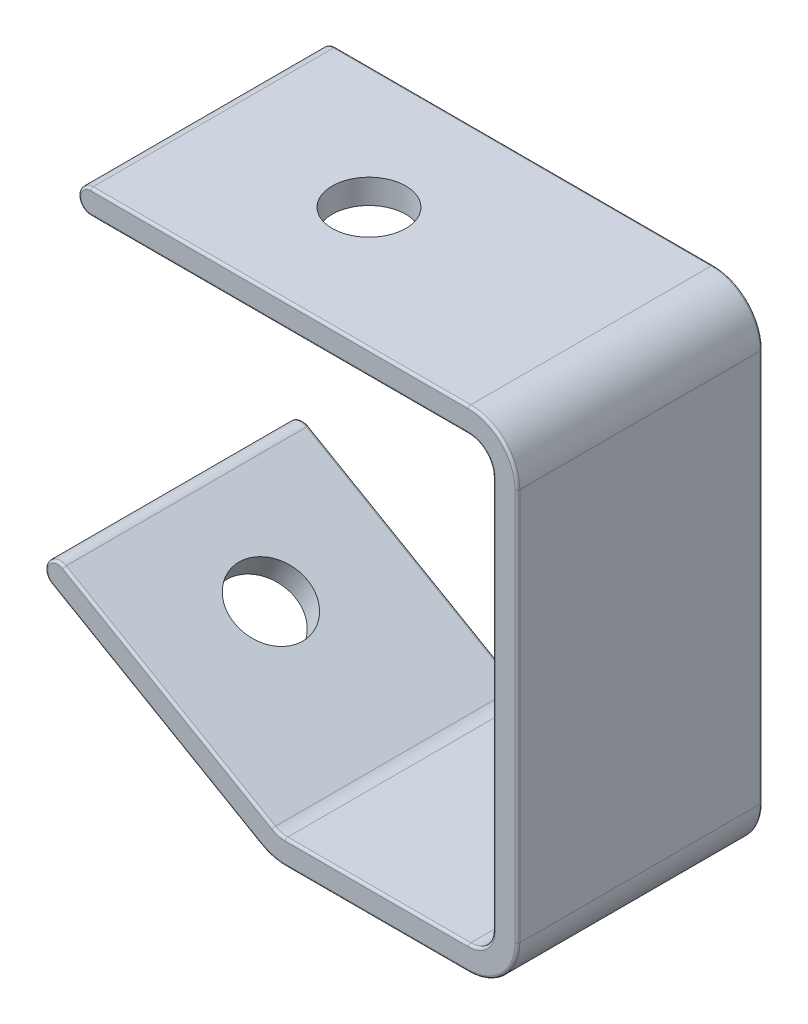
from build123d import *

# Parameters (mm, degrees)
EXTRUDE_1_DEPTH     = 25
SKETCH_3_R          = 7.5
CUT_EXTRUDE_1_DEPTH = 5
SKETCH_5_R          = 7.5
CUT_EXTRUDE_2_DEPTH = 5
FILLET_1_R          = 0.5


with BuildPart() as part:
    # 草图1 → 凸台-拉伸1 (new body, symmetric)
    with BuildSketch(Plane.XY):
        with BuildLine():
            Line((0, 10), (0, 90))
            ThreePointArc((0, 90), (-2.928932188, 97.071067812), (-10, 100))
            Line((-10, 100), (-87, 100))
            ThreePointArc((-87, 100), (-89.5, 97.5), (-87, 95))
            Line((-87, 95), (-10, 95))
            ThreePointArc((-10, 95), (-6.464466094, 93.535533906), (-5, 90))
            Line((-5, 90), (-5, 10))
            ThreePointArc((-5, 10), (-6.464466094, 6.464466094), (-10, 5))
            Line((-10, 5), (-47.320508076, 5))
            ThreePointArc((-47.320508076, 5), (-48.614603301, 5.170370869), (-49.820508076, 5.669872981))
            Line((-49.820508076, 5.669872981), (-92.5, 30.310889132))
            ThreePointArc((-92.5, 30.310889132), (-95.915063509, 29.395825623), (-95, 25.980762114))
            Line((-95, 25.980762114), (-52.320508076, 1.339745962))
            ThreePointArc((-52.320508076, 1.339745962), (-49.908698527, 0.340741737), (-47.320508076, 0))
            Line((-47.320508076, 0), (-10, 0))
            ThreePointArc((-10, 0), (-2.928932188, 2.928932188), (0, 10))
        make_face()
    extrude(amount=EXTRUDE_1_DEPTH, both=True)

    # 草图3 → 切除-拉伸1 (cut)
    with BuildSketch(Plane(origin=(-10, -17.320508076, 0), x_dir=(0.866025404, -0.5, 0), z_dir=(0.5, 0.866025404, 0))):
        with Locations((-75.358983849, 0)):
            Circle(SKETCH_3_R)
    extrude(amount=-CUT_EXTRUDE_1_DEPTH, mode=Mode.SUBTRACT)

    # 草图5 → 切除-拉伸2 (cut)
    with BuildSketch(Plane(origin=(0, 100, 0), x_dir=(1, 0, 0), z_dir=(0, 1, 0))):
        with Locations((-55.262794416, 0)):
            Circle(SKETCH_5_R)
    extrude(amount=-CUT_EXTRUDE_2_DEPTH, mode=Mode.SUBTRACT)

    # 圆角1
    fillet_1_edges = [part.edges().sort_by_distance(p)[0] for p in [
        (-89.5, 97.5, 25),
        (0, 50, -25),
        (-2.928932188, 2.928932188, -25),
        (-28.660254038, 0, -25),
        (-48.5, 95, 25),
        (-49.908698527, 0.340741737, -25),
        (-73.660254038, 13.660254038, -25),
        (-95.915063509, 29.395825623, -25),
        (-71.160254038, 17.990381057, -25),
        (-48.614603301, 5.170370869, -25),
        (-28.660254038, 5, -25),
        (-6.464466094, 6.464466094, -25),
        (-5, 50, -25),
        (-6.464466094, 93.535533906, -25),
        (-48.5, 95, -25),
        (-6.464466094, 93.535533906, 25),
        (-89.5, 97.5, -25),
        (-48.5, 100, -25),
        (-2.928932188, 97.071067812, -25),
        (-5, 50, 25),
        (-6.464466094, 6.464466094, 25),
        (-28.660254038, 5, 25),
        (-48.614603301, 5.170370869, 25),
        (-71.160254038, 17.990381057, 25),
        (-95.915063509, 29.395825623, 25),
        (-73.660254038, 13.660254038, 25),
        (-2.928932188, 97.071067812, 25),
        (-49.908698527, 0.340741737, 25),
        (-28.660254038, 0, 25),
        (-2.928932188, 2.928932188, 25),
        (0, 50, 25),
        (-48.5, 100, 25),
    ]]
    fillet(fillet_1_edges, radius=FILLET_1_R)


solid = part.part
